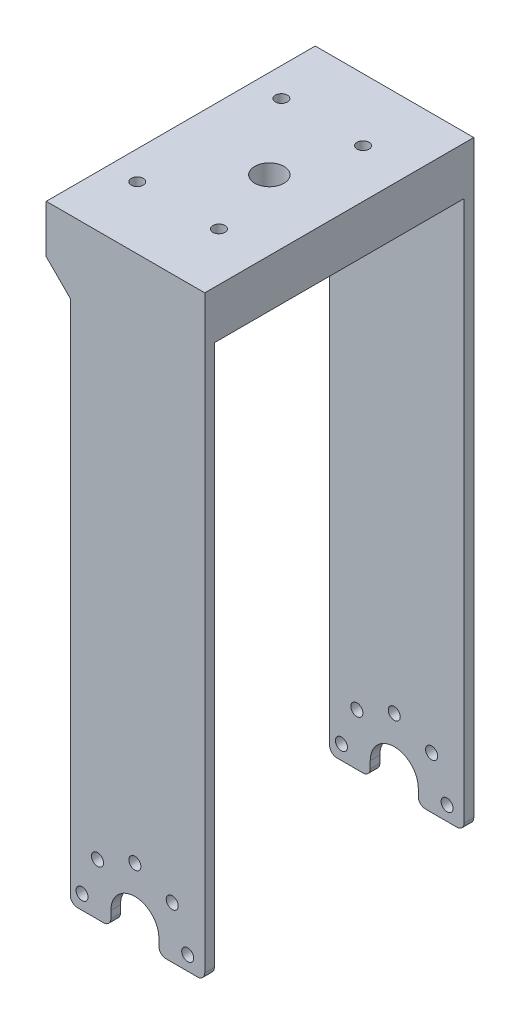
from build123d import *

# Parameters (mm, degrees)
SKETCH1_W               = 28
SKETCH1_H               = 124.1
BOSS_EXTRUDE1_DEPTH     = 2
CUT_EXTRUDE2_DEPTH      = 1
CUT_EXTRUDE2_DEPTH_BACK = 2
SKETCH4_R               = 1.25
CUT_EXTRUDE3_DEPTH      = 2
CIRPATTERN1_COUNT       = 5
CIRPATTERN1_ANGLE       = 180
FILLET1_R               = 1.5
SKETCH7_W               = 28
SKETCH7_H               = 124.1
BOSS_EXTRUDE2_DEPTH     = 2
CUT_EXTRUDE4_DEPTH      = 1
CUT_EXTRUDE4_DEPTH_BACK = 2
SKETCH11_R              = 1.25
CUT_EXTRUDE5_DEPTH      = 2
CIRPATTERN2_COUNT       = 5
CIRPATTERN2_ANGLE       = 180
FILLET2_R               = 1.5
SKETCH17_W              = 33
SKETCH17_H              = 52
BOSS_EXTRUDE5_DEPTH     = 15
CUT_EXTRUDE7_REACH      = 126.1
SKETCH18_R              = 3.05
SKETCH19_R              = 1.25
CUT_EXTRUDE8_DEPTH      = 10
SKETCH20_W              = 29.100039055
SKETCH20_H              = 52
CUT_EXTRUDE9_DEPTH      = 5
SKETCH21_W              = 5
SKETCH21_H              = 15
BOSS_EXTRUDE6_DEPTH     = 2
SKETCH22_W              = 52
SKETCH22_H              = 5
CUT_EXTRUDE10_DEPTH     = 2.95
SKETCH23_W              = 52
SKETCH23_H              = 5
CUT_EXTRUDE11_DEPTH     = 2.949960945
CUT_EXTRUDE12_DEPTH     = 3
SKETCH25_R              = 2.5
CUT_EXTRUDE13_DEPTH     = 5


with BuildPart() as part:
    # Sketch1 → Boss-Extrude1 (new body)
    with BuildSketch(Plane.XY):
        with Locations((14, 62.05)):
            Rectangle(SKETCH1_W, SKETCH1_H)
    extrude(amount=-BOSS_EXTRUDE1_DEPTH)

    # Sketch3 → Cut-Extrude2 (cut, two sides)
    with BuildSketch(Plane.XY) as cut_extrude2_sk:
        with BuildLine():
            Line((18.449960945, -261.260932316), (18.449960945, 0))
            Line((18.449960945, 0), (18.449960945, 3))
            ThreePointArc((18.449960945, 3), (13.449960945, 8), (8.449960945, 3))
            Line((8.449960945, 3), (8.449960945, 0))
            Line((8.449960945, 0), (8.449960945, -261.260932316))
            Line((8.449960945, -261.260932316), (8.449960945, -783.782796947))
            Line((8.449960945, -783.782796947), (18.449960945, -783.782796947))
            Line((18.449960945, -783.782796947), (18.449960945, -261.260932316))
        make_face()
    extrude(amount=CUT_EXTRUDE2_DEPTH, mode=Mode.SUBTRACT)
    extrude(cut_extrude2_sk.sketch, amount=-CUT_EXTRUDE2_DEPTH_BACK, mode=Mode.SUBTRACT)

    # Sketch4 → Cut-Extrude3 (cut)
    with BuildSketch(Plane.XY):
        with Locations((2.449960945, 3)):
            Circle(SKETCH4_R)
    cut_extrude3 = extrude(amount=-CUT_EXTRUDE3_DEPTH, mode=Mode.SUBTRACT)

    # CirPattern1: Cut-Extrude3 ×5 about axis
    cirpattern1_axis = Axis((13.449960945, 3, 0), (0, 0, -1))
    for i in range(1, CIRPATTERN1_COUNT):
        add(cut_extrude3.rotate(cirpattern1_axis, i * CIRPATTERN1_ANGLE / (CIRPATTERN1_COUNT - 1)), mode=Mode.SUBTRACT)

    # Fillet1
    fillet1_edges = [part.edges().sort_by_distance(p)[0] for p in [
        (18.449960945, 0, -1),
        (8.449960945, 0, -1),
        (28, 0, -1),
        (0, 0, -1),
    ]]
    fillet(fillet1_edges, radius=FILLET1_R)



with BuildPart() as body_2:
    # Sketch7 → Boss-Extrude2 (new body)
    with BuildSketch(Plane.XY.offset(-56)):
        with Locations((14, 62.05)):
            Rectangle(SKETCH7_W, SKETCH7_H)
    extrude(amount=BOSS_EXTRUDE2_DEPTH)

    # Sketch10 → Cut-Extrude4 (cut, two sides)
    with BuildSketch(Plane(origin=(0, 0, -56), x_dir=(-1, 0, 0), z_dir=(0, 0, -1))) as cut_extrude4_sk:
        with BuildLine():
            Line((-8.449960945, -261.260932316), (-8.449960945, 0))
            Line((-8.449960945, 0), (-8.449960945, 3))
            ThreePointArc((-8.449960945, 3), (-13.449960945, 8), (-18.449960945, 3))
            Line((-18.449960945, 3), (-18.449960945, 0))
            Line((-18.449960945, 0), (-18.449960945, -261.260932316))
            Line((-18.449960945, -261.260932316), (-18.449960945, -783.782796947))
            Line((-18.449960945, -783.782796947), (-8.449960945, -783.782796947))
            Line((-8.449960945, -783.782796947), (-8.449960945, -261.260932316))
        make_face()
    extrude(amount=CUT_EXTRUDE4_DEPTH, mode=Mode.SUBTRACT)
    extrude(cut_extrude4_sk.sketch, amount=-CUT_EXTRUDE4_DEPTH_BACK, mode=Mode.SUBTRACT)

    # Sketch11 → Cut-Extrude5 (cut)
    with BuildSketch(Plane(origin=(0, 0, -56), x_dir=(-1, 0, 0), z_dir=(0, 0, -1))):
        with Locations((-24.449960945, 3)):
            Circle(SKETCH11_R)
    cut_extrude5 = extrude(amount=-CUT_EXTRUDE5_DEPTH, mode=Mode.SUBTRACT)

    # CirPattern2: Cut-Extrude5 ×5 about axis
    cirpattern2_axis = Axis((13.449960945, 3, 0), (0, 0, 1))
    for i in range(1, CIRPATTERN2_COUNT):
        add(cut_extrude5.rotate(cirpattern2_axis, i * CIRPATTERN2_ANGLE / (CIRPATTERN2_COUNT - 1)), mode=Mode.SUBTRACT)

    # Fillet2
    fillet2_edges = [body_2.edges().sort_by_distance(p)[0] for p in [
        (8.449960945, 0, -55),
        (18.449960945, 0, -55),
        (28, 0, -55),
        (0, 0, -55),
    ]]
    fillet(fillet2_edges, radius=FILLET2_R)


with BuildPart() as part_1:
    add(part.part)

    add(body_2.part)  # Boss-Extrude5 merges body 2
    # Sketch17 → Boss-Extrude5 (add)
    with BuildSketch(Plane(origin=(0, 124.1, 0), x_dir=(1, 0, 0), z_dir=(0, 1, 0))):
        with Locations((11.5, 28)):
            Rectangle(SKETCH17_W, SKETCH17_H)
    extrude(amount=-BOSS_EXTRUDE5_DEPTH)

    # Sketch18 → Cut-Extrude7 (cut, up to next)
    with BuildSketch(Plane(origin=(0, 124.1, 0), x_dir=(1, 0, 0), z_dir=(0, 1, 0)), mode=Mode.PRIVATE) as cut_extrude7_sk1:
        with Locations((13.449960945, 28)):
            Circle(SKETCH18_R)
    cut_extrude7_tool1 = extrude(cut_extrude7_sk1.sketch, amount=-CUT_EXTRUDE7_REACH, mode=Mode.PRIVATE) & part_1.part
    add(cut_extrude7_tool1.solids().sort_by_distance((13.449961, 124.1, -28))[0], mode=Mode.SUBTRACT)

    # Sketch19 → Cut-Extrude8 (cut)
    with BuildSketch(Plane(origin=(0, 124.1, 0), x_dir=(1, 0, 0), z_dir=(0, 1, 0))):
        with Locations((0.949960945, 43)):
            Circle(SKETCH19_R)
        with Locations((17.949960945, 43)):
            Circle(SKETCH19_R)
    cut_extrude8 = extrude(amount=-CUT_EXTRUDE8_DEPTH, mode=Mode.SUBTRACT)

    # Mirror9: Cut-Extrude8 across plane
    add(cut_extrude8.mirror(Plane(origin=(0, 0, -28), x_dir=(1, 0, 0), z_dir=(0, 0, -1))), mode=Mode.SUBTRACT)

    # Sketch20 → Cut-Extrude9 (cut)
    with BuildSketch(Plane.XZ.offset(-109.1)):
        with Locations((11.499980473, -28)):
            Rectangle(SKETCH20_W, SKETCH20_H)
    extrude(amount=-CUT_EXTRUDE9_DEPTH, mode=Mode.SUBTRACT)

    # Sketch21 → Boss-Extrude6 (add)
    with BuildSketch(Plane.XY.offset(-2)):
        with Locations((-2.5, 116.6)):
            Rectangle(SKETCH21_W, SKETCH21_H)
    boss_extrude6 = extrude(amount=BOSS_EXTRUDE6_DEPTH)

    # Mirror10: Boss-Extrude6 across plane
    add(boss_extrude6.mirror(Plane(origin=(0, 0, -28), x_dir=(1, 0, 0), z_dir=(0, 0, -1))))

    # Sketch22 → Cut-Extrude10 (cut, through all)
    with BuildSketch(Plane.ZY.offset(-26.05)):
        with Locations((-28, 111.6)):
            Rectangle(SKETCH22_W, SKETCH22_H)
    extrude(amount=-CUT_EXTRUDE10_DEPTH, mode=Mode.SUBTRACT)

    # Sketch23 → Cut-Extrude11 (cut, through all)
    with BuildSketch(Plane(origin=(-3.050039055, 0, 0), x_dir=(0, 0, -1), z_dir=(1, 0, 0))):
        with Locations((28, 111.6)):
            Rectangle(SKETCH23_W, SKETCH23_H)
    extrude(amount=-CUT_EXTRUDE11_DEPTH, mode=Mode.SUBTRACT)

    # Sketch24 → Cut-Extrude12 (cut, through all)
    with BuildSketch(Plane(origin=(0, 0, -2), x_dir=(-1, 0, 0), z_dir=(0, 0, -1))):
        Polygon((0, 109.1), (5, 114.1), (5, 109.1), align=None)
    cut_extrude12 = extrude(amount=-CUT_EXTRUDE12_DEPTH, mode=Mode.SUBTRACT)

    # Mirror11: Cut-Extrude12 across plane
    add(cut_extrude12.mirror(Plane(origin=(0, 0, -28), x_dir=(1, 0, 0), z_dir=(0, 0, -1))), mode=Mode.SUBTRACT)

    # Sketch25 → Cut-Extrude13 (cut)
    with BuildSketch(Plane.XZ.offset(-114.1)):
        with Locations((0.949960945, -43)):
            Circle(SKETCH25_R)
        with Locations((17.949960945, -43)):
            Circle(SKETCH25_R)
    cut_extrude13 = extrude(amount=-CUT_EXTRUDE13_DEPTH, mode=Mode.SUBTRACT)

    # Mirror12: Cut-Extrude13 across plane
    add(cut_extrude13.mirror(Plane(origin=(0, 0, -28), x_dir=(1, 0, 0), z_dir=(0, 0, -1))), mode=Mode.SUBTRACT)


solid = part_1.part
